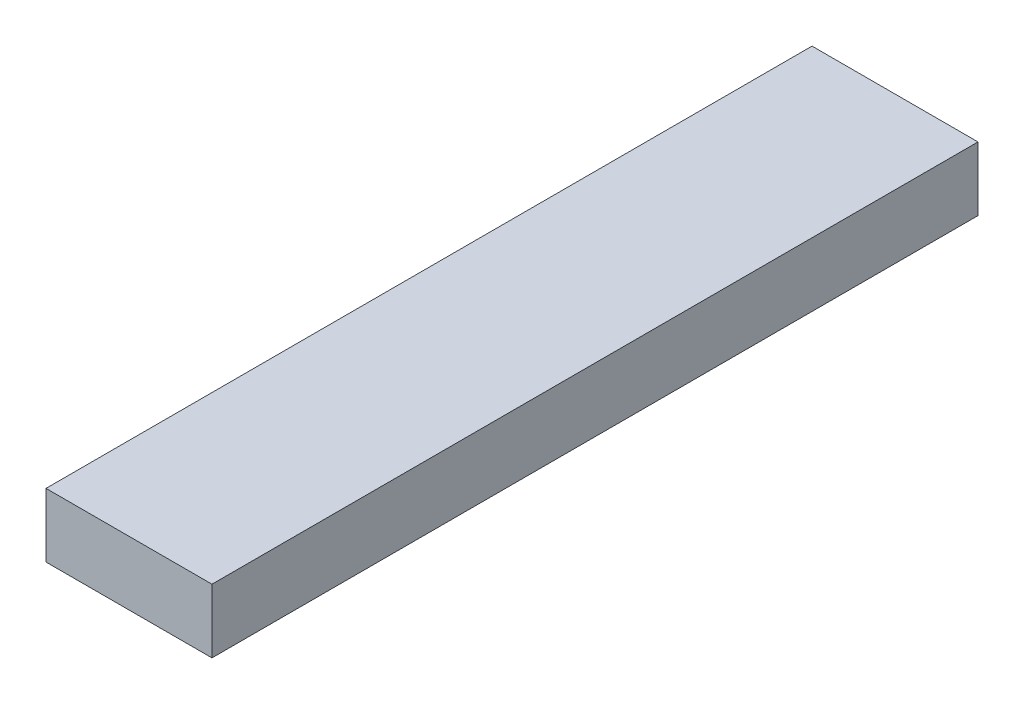
from build123d import *

# Parameters (mm, degrees)
ESQUISSE1_W        = 13
ESQUISSE1_H        = 5
BOSS_EXTRU_1_DEPTH = 60


with BuildPart() as part:
    # Esquisse1 → Boss.-Extru.1 (new body)
    with BuildSketch(Plane.XY):
        with Locations((6.5, -2.5)):
            Rectangle(ESQUISSE1_W, ESQUISSE1_H)
    extrude(amount=BOSS_EXTRU_1_DEPTH)


solid = part.part
